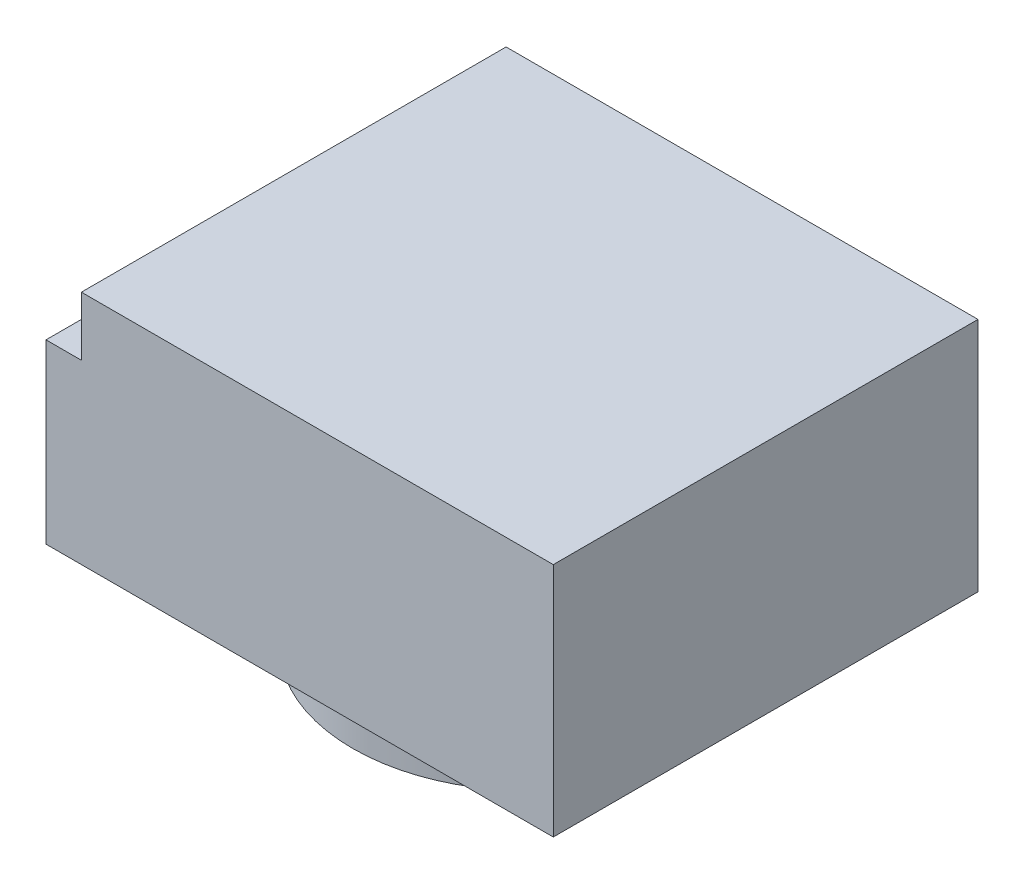
from build123d import *

# Parameters (mm, degrees)
CROQUIS1_W                   = 40
CROQUIS1_H                   = 36
SALIENTE_EXTRUIR1_DEPTH      = 20
CROQUIS3_W                   = 3
CROQUIS3_H                   = 15
SALIENTE_EXTRUIR2_DEPTH      = 18
SALIENTE_EXTRUIR2_DEPTH_BACK = 18


with BuildPart() as part:
    # Croquis1 → Saliente-Extruir1 (new body)
    with BuildSketch(Plane(origin=(0, 0, 0), x_dir=(1, 0, 0), z_dir=(0, 1, 0))):
        Rectangle(CROQUIS1_W, CROQUIS1_H)
    extrude(amount=SALIENTE_EXTRUIR1_DEPTH)

    # Croquis2 → Revolución1 (revolve)
    with BuildSketch(Plane(origin=(0, 0, 0), x_dir=(0, 0, -1), z_dir=(1, 0, 0))):
        Polygon((0, 0), (-15, 1.022668877), (-15, -5), (0, -5), align=None)
    revolve(axis=Axis((0, 0, 0), (0, -1, 0)))

    # Croquis3 → Saliente-Extruir2 (add, two sides)
    with BuildSketch(Plane.XY) as saliente_extruir2_sk:
        with Locations((-21.5, 7.5)):
            Rectangle(CROQUIS3_W, CROQUIS3_H)
    extrude(amount=SALIENTE_EXTRUIR2_DEPTH)
    extrude(saliente_extruir2_sk.sketch, amount=-SALIENTE_EXTRUIR2_DEPTH_BACK)


solid = part.part
